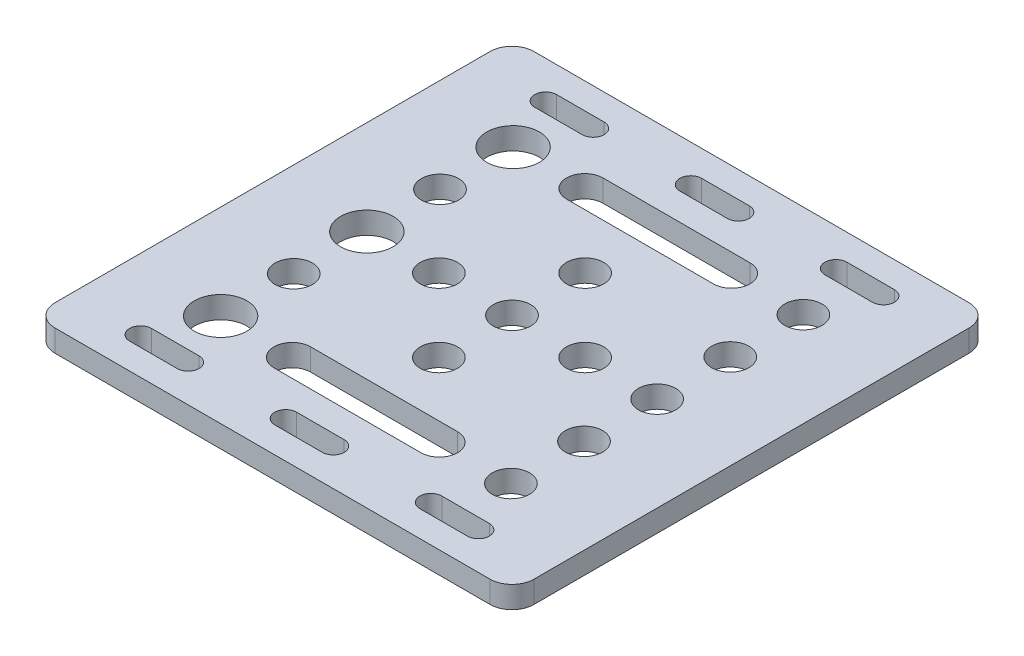
from build123d import *

# Parameters (mm, degrees)
SKETCH1_W            = 65.5
SKETCH1_H            = 65.5
BOSS_EXTRUDE1_DEPTH  = 3
SKETCH5_R            = 2.55
CUT_EXTRUDE5_DEPTH   = 4
LPATTERN2_COUNT      = 5
LPATTERN2_PITCH      = 10
LPATTERN2_COUNT_DIR2 = 2
LPATTERN2_PITCH_DIR2 = 39.7
SKETCH7_R            = 2.55
CUT_EXTRUDE6_DEPTH   = 4
SKETCH8_R            = 2.55
CUT_EXTRUDE7_DEPTH   = 4
CIRPATTERN1_COUNT    = 4
CUT_EXTRUDE4_START   = -1
SKETCH3_R            = 3.6
CUT_EXTRUDE4_DEPTH   = 5
LPATTERN1_COUNT      = 3
LPATTERN1_PITCH      = 20
CUT_EXTRUDE8_DEPTH   = 4
LPATTERN3_COUNT      = 3
LPATTERN3_PITCH      = 19.85
LPATTERN3_COUNT_DIR2 = 2
LPATTERN3_PITCH_DIR2 = 55.4
CUT_EXTRUDE9_DEPTH   = 4
LPATTERN4_COUNT      = 2
LPATTERN4_PITCH      = 40
FILLET1_R            = 3


with BuildPart() as part:
    # Sketch1 → Boss-Extrude1 (new body)
    with BuildSketch(Plane(origin=(0, 0, 0), x_dir=(1, 0, 0), z_dir=(0, 1, 0))):
        Rectangle(SKETCH1_W, SKETCH1_H)
    extrude(amount=BOSS_EXTRUDE1_DEPTH)

    # Sketch5 → Cut-Extrude5 (cut, through all)
    with BuildSketch(Plane(origin=(0, 0, 0), x_dir=(1, 0, 0), z_dir=(0, 1, 0))):
        with Locations((-19.85, 20)):
            Circle(SKETCH5_R)
    cut_extrude5 = extrude(amount=CUT_EXTRUDE5_DEPTH, mode=Mode.SUBTRACT)

    # LPattern2: Cut-Extrude5 5 × 2
    with Locations(*[(j * LPATTERN2_PITCH_DIR2, 0, i * LPATTERN2_PITCH) for i in range(LPATTERN2_COUNT) for j in range(LPATTERN2_COUNT_DIR2) if (i, j) != (0, 0)]):
        add(cut_extrude5, mode=Mode.SUBTRACT)

    # Sketch7 → Cut-Extrude6 (cut, through all)
    with BuildSketch(Plane(origin=(0, 0, 0), x_dir=(1, 0, 0), z_dir=(0, 1, 0))):
        Circle(SKETCH7_R)
    extrude(amount=CUT_EXTRUDE6_DEPTH, mode=Mode.SUBTRACT)

    # Sketch8 → Cut-Extrude7 (cut, through all)
    with BuildSketch(Plane(origin=(0, 0, 0), x_dir=(1, 0, 0), z_dir=(0, 1, 0))):
        with Locations((0, 10)):
            Circle(SKETCH8_R)
    cut_extrude7 = extrude(amount=CUT_EXTRUDE7_DEPTH, mode=Mode.SUBTRACT)

    # CirPattern1: Cut-Extrude7 ×4 about axis
    cirpattern1_axis = Axis((0, 0, 0), (0, 1, 0))
    for i in range(1, CIRPATTERN1_COUNT):
        add(cut_extrude7.rotate(cirpattern1_axis, i * 360 / CIRPATTERN1_COUNT), mode=Mode.SUBTRACT)

    # Sketch3 → Cut-Extrude4 (cut)
    with BuildSketch(Plane(origin=(0, 0, 0), x_dir=(1, 0, 0), z_dir=(0, 1, 0)).offset(CUT_EXTRUDE4_START)):
        with Locations((-19.85, 20)):
            Circle(SKETCH3_R)
    cut_extrude4 = extrude(amount=CUT_EXTRUDE4_DEPTH, mode=Mode.SUBTRACT)

    # LPattern1: Cut-Extrude4 ×3
    with Locations(*[(0, 0, i * LPATTERN1_PITCH) for i in range(1, LPATTERN1_COUNT)]):
        add(cut_extrude4, mode=Mode.SUBTRACT)

    # Sketch9 → Cut-Extrude8 (cut, through all)
    with BuildSketch(Plane(origin=(0, 0, 0), x_dir=(1, 0, 0), z_dir=(0, 1, 0))):
        with BuildLine():
            Line((-23.1, 29.2), (-16.6, 29.2))
            ThreePointArc((-16.6, 29.2), (-15.1, 27.7), (-16.6, 26.2))
            Line((-16.6, 26.2), (-23.1, 26.2))
            ThreePointArc((-23.1, 26.2), (-24.6, 27.7), (-23.1, 29.2))
        make_face()
    cut_extrude8 = extrude(amount=CUT_EXTRUDE8_DEPTH, mode=Mode.SUBTRACT)

    # LPattern3: Cut-Extrude8 3 × 2
    with Locations(*[(i * LPATTERN3_PITCH, 0, j * LPATTERN3_PITCH_DIR2) for i in range(LPATTERN3_COUNT) for j in range(LPATTERN3_COUNT_DIR2) if (i, j) != (0, 0)]):
        add(cut_extrude8, mode=Mode.SUBTRACT)

    # Sketch10 → Cut-Extrude9 (cut, through all)
    with BuildSketch(Plane(origin=(0, 0, 0), x_dir=(1, 0, 0), z_dir=(0, 1, 0))):
        with BuildLine():
            Line((-10.05, 22.5), (10.05, 22.5))
            ThreePointArc((10.05, 22.5), (12.55, 20), (10.05, 17.5))
            Line((10.05, 17.5), (-10.05, 17.5))
            ThreePointArc((-10.05, 17.5), (-12.55, 20), (-10.05, 22.5))
        make_face()
    cut_extrude9 = extrude(amount=CUT_EXTRUDE9_DEPTH, mode=Mode.SUBTRACT)

    # LPattern4: Cut-Extrude9 ×2
    with Locations(*[(0, 0, i * LPATTERN4_PITCH) for i in range(1, LPATTERN4_COUNT)]):
        add(cut_extrude9, mode=Mode.SUBTRACT)

    # Fillet1
    fillet1_edges = [part.edges().sort_by_distance(p)[0] for p in [
        (32.75, 1.5, 32.75),
        (-32.75, 1.5, 32.75),
        (-32.75, 1.5, -32.75),
        (32.75, 1.5, -32.75),
    ]]
    fillet(fillet1_edges, radius=FILLET1_R)


solid = part.part
